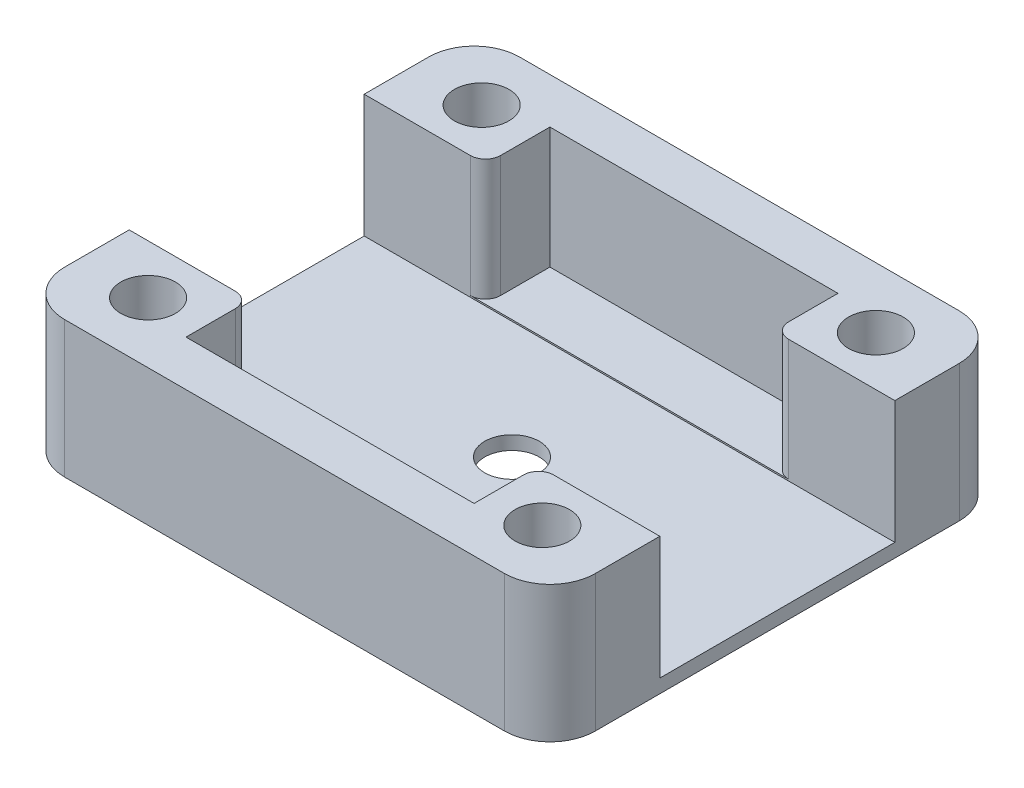
from build123d import *

# Parameters (mm, degrees)
SKETCH1_W            = 35
SKETCH1_H            = 30
BOSS_EXTRUDE1_DEPTH  = 9
SKETCH3_W            = 29
SKETCH3_H            = 24
CUT_EXTRUDE1_DEPTH   = 8
SKETCH4_W            = 15.5
SKETCH4_H            = 8.1
CUT_EXTRUDE2_DEPTH   = 36
SKETCH5_W            = 5
SKETCH5_H            = 4.25
BOSS_EXTRUDE2_DEPTH  = 8
M3_CLEARANCE_HOLE1_D = 3.6
FILLET1_R            = 3
FILLET2_R            = 1


with BuildPart() as part:
    # Sketch1 → Boss-Extrude1 (new body)
    with BuildSketch(Plane(origin=(0, 0, 0), x_dir=(1, 0, 0), z_dir=(0, 1, 0))):
        Rectangle(SKETCH1_W, SKETCH1_H)
    extrude(amount=BOSS_EXTRUDE1_DEPTH)

    # Sketch3 → Cut-Extrude1 (cut)
    with BuildSketch(Plane(origin=(0, 9, 0), x_dir=(1, 0, 0), z_dir=(0, 1, 0))):
        Rectangle(SKETCH3_W, SKETCH3_H)
    extrude(amount=-CUT_EXTRUDE1_DEPTH, mode=Mode.SUBTRACT)

    # Sketch4 → Cut-Extrude2 (cut, through all)
    with BuildSketch(Plane.ZY.offset(17.5)):
        with Locations((0, 4.95)):
            Rectangle(SKETCH4_W, SKETCH4_H)
    extrude(amount=-CUT_EXTRUDE2_DEPTH, mode=Mode.SUBTRACT)

    # Sketch5 → Boss-Extrude2 (add)
    with BuildSketch(Plane(origin=(0, 1, 0), x_dir=(1, 0, 0), z_dir=(0, 1, 0))):
        with Locations((-12, 9.875)):
            Rectangle(SKETCH5_W, SKETCH5_H)
        with Locations((12, 9.875)):
            Rectangle(SKETCH5_W, SKETCH5_H)
        with Locations((12, -9.875)):
            Rectangle(SKETCH5_W, SKETCH5_H)
        with Locations((-12, -9.875)):
            Rectangle(SKETCH5_W, SKETCH5_H)
    extrude(amount=BOSS_EXTRUDE2_DEPTH)

    # M3 Clearance Hole1 (through all)
    with Locations(Plane(origin=(0, 9, 0), x_dir=(1, 0, 0), z_dir=(0, 1, 0))):
        with Locations((0, 0), (13, 11), (-13, -11), (-13, 11), (13, -11)):
            Hole(M3_CLEARANCE_HOLE1_D / 2)

    # Fillet1
    fillet1_edges = [part.edges().sort_by_distance(p)[0] for p in [
        (17.5, 4.5, 15),
        (-17.5, 4.5, 15),
        (-17.5, 4.5, -15),
        (17.5, 4.5, -15),
    ]]
    fillet(fillet1_edges, radius=FILLET1_R)

    # Fillet2
    fillet2_edges = [part.edges().sort_by_distance(p)[0] for p in [
        (-9.5, 5, -7.75),
        (9.5, 5, -7.75),
        (9.5, 5, 7.75),
        (-9.5, 5, 7.75),
    ]]
    fillet(fillet2_edges, radius=FILLET2_R)


solid = part.part
